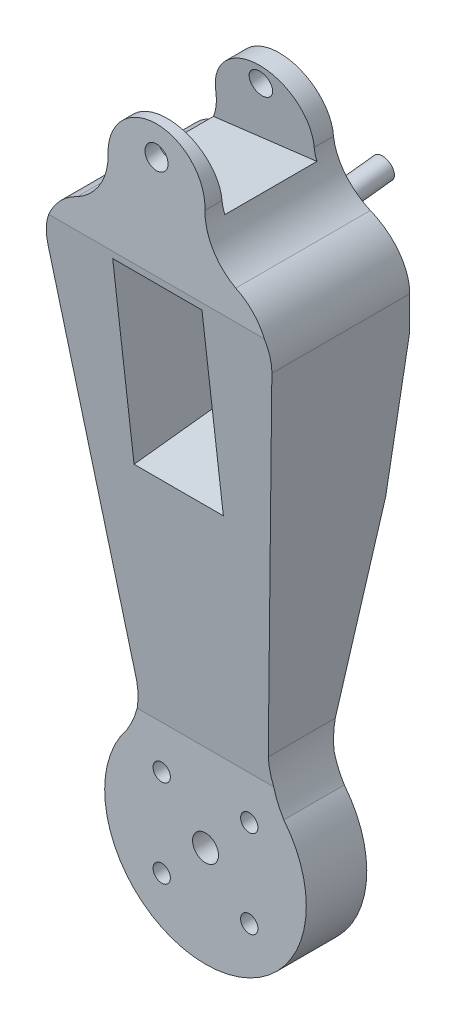
from build123d import *

# Parameters (mm, degrees)
BOSS_EXTRUDE1_DEPTH     = 55
CUT_EXTRUDE3_DEPTH      = 28
CUT_EXTRUDE4_DEPTH      = 40.029131656
CUT_EXTRUDE4_DEPTH_BACK = 40.029131656
SKETCH18_R              = 4.5
SKETCH18_R_2            = 3
CUT_EXTRUDE5_DEPTH      = 24.598674983
CUT_EXTRUDE5_DEPTH_BACK = 28
CUT_EXTRUDE6_DEPTH      = 26.134831719
CUT_EXTRUDE6_DEPTH_BACK = 85.175442033
SKETCH21_R              = 4
CUT_EXTRUDE7_DEPTH      = 25.226187847
CUT_EXTRUDE7_DEPTH_BACK = 56.443633682
SKETCH22_W              = 31
SKETCH22_H              = 66
CUT_EXTRUDE8_DEPTH      = 34
SKETCH30_R              = 3.775
BOSS_EXTRUDE2_DEPTH     = 30
CUT_EXTRUDE9_START      = 20
CUT_EXTRUDE9_DEPTH      = 15


with BuildPart() as part:
    # Sketch1 → Boss-Extrude1 (new body)
    with BuildSketch(Plane.XY):
        with BuildLine():
            Line((-22.827528122, 39.292617223), (-38.880054689, 170.029954628))
            ThreePointArc((-38.880054689, 170.029954628), (-36.535345881, 182.138559801), (-27.533199801, 190.569297881))
            ThreePointArc((-27.533199801, 190.569297881), (-19.660174006, 198.055084384), (-16.79086128, 208.533088928))
            ThreePointArc((-16.79086128, 208.533088928), (0, 226.212902341), (16.79086128, 208.533088928))
            ThreePointArc((16.79086128, 208.533088928), (19.660174006, 198.055084384), (27.533199801, 190.569297881))
            ThreePointArc((27.533199801, 190.569297881), (36.535345881, 182.138559801), (38.880054689, 170.029954628))
            Line((38.880054689, 170.029954628), (22.827528122, 39.292617223))
            ThreePointArc((22.827528122, 39.292617223), (23.667809595, 30.306601974), (27.215074691, 22.007719318))
            ThreePointArc((27.215074691, 22.007719318), (0, -35), (-27.215074691, 22.007719318))
            ThreePointArc((-27.215074691, 22.007719318), (-23.667809595, 30.306601974), (-22.827528122, 39.292617223))
        make_face()
    extrude(amount=BOSS_EXTRUDE1_DEPTH)

    # Sketch5 → Cut-Extrude3 (cut)
    with BuildSketch(Plane.XY):
        Polygon((16.97, -20.5), (-16.97, -20.5), (-20.5, -16.97), (-20.5, 16.97), (-16.97, 20.5), (16.97, 20.5), (20.5, 16.97), (20.5, -16.97), align=None)
    extrude(amount=CUT_EXTRUDE3_DEPTH, mode=Mode.SUBTRACT)

    # Sketch15 → Cut-Extrude4 (cut, two sides)
    with BuildSketch(Plane(origin=(0, 0, 0), x_dir=(0, 0, -1), z_dir=(1, 0, 0))) as cut_extrude4_sk:
        Polygon((-38, -35), (-38, 30.17907071), (-55, 180.299626254), (-55, -35), align=None)
        Polygon((-4.401325017, 156.123614829), (-12.400064416, 226.757450259), (0, 226.212902341), (0, 149.914783233), (0, 117.257182084), (0, -35), (-17, -35), (-17, 30.65016827), (-6.349536626, 105.369192589), align=None)
    extrude(amount=CUT_EXTRUDE4_DEPTH, mode=Mode.SUBTRACT)
    extrude(cut_extrude4_sk.sketch, amount=-CUT_EXTRUDE4_DEPTH_BACK, mode=Mode.SUBTRACT)

    # Sketch18 → Cut-Extrude5 (cut, two sides)
    with BuildSketch(Plane(origin=(0, 0, 28), x_dir=(-1, 0, 0), z_dir=(0, 0, -1))) as cut_extrude5_sk:
        Circle(SKETCH18_R)
        with Locations((-15.199466094, 15.199466094)):
            Circle(SKETCH18_R_2)
        with Locations((15.199466094, 15.199466094)):
            Circle(SKETCH18_R_2)
        with Locations((15.199466094, -15.199466094)):
            Circle(SKETCH18_R_2)
        with Locations((-15.199466094, -15.199466094)):
            Circle(SKETCH18_R_2)
    extrude(amount=CUT_EXTRUDE5_DEPTH, mode=Mode.SUBTRACT)
    extrude(cut_extrude5_sk.sketch, amount=-CUT_EXTRUDE5_DEPTH_BACK, mode=Mode.SUBTRACT)

    # Sketch20 → Cut-Extrude6 (cut, two sides)
    with BuildSketch(Plane(origin=(-17.735618329, -2.177660109, 0), x_dir=(0, 0, 1), z_dir=(-0.992546152, -0.121869343, 0))) as cut_extrude6_sk:
        Polygon((16.527188649, 200.652068787), (48.527188649, 200.652068787), (51.520800543, 224.652068787), (19.520800543, 224.652068787), align=None)
    extrude(amount=CUT_EXTRUDE6_DEPTH, mode=Mode.SUBTRACT)
    extrude(cut_extrude6_sk.sketch, amount=-CUT_EXTRUDE6_DEPTH_BACK, mode=Mode.SUBTRACT)

    # Sketch21 → Cut-Extrude7 (cut, two sides)
    with BuildSketch(Plane(origin=(0, -3.866612347, 34.144587862), x_dir=(1, 0, 0), z_dir=(0, -0.11252313, 0.993649106))) as cut_extrude7_sk:
        with Locations((0, 220.965020256)):
            Circle(SKETCH21_R)
    extrude(amount=CUT_EXTRUDE7_DEPTH, mode=Mode.SUBTRACT)
    extrude(cut_extrude7_sk.sketch, amount=-CUT_EXTRUDE7_DEPTH_BACK, mode=Mode.SUBTRACT)

    # Sketch22 → Cut-Extrude8 (cut)
    with BuildSketch(Plane(origin=(0, -3.866612347, 34.144587862), x_dir=(1, 0, 0), z_dir=(0, -0.11252313, 0.993649106))):
        with Locations((0, 149.850276465)):
            Rectangle(SKETCH22_W, SKETCH22_H)
    extrude(amount=-CUT_EXTRUDE8_DEPTH, mode=Mode.SUBTRACT)

    # Sketch30 → Boss-Extrude2 (add)
    with BuildSketch(Plane(origin=(0, 1.484646511, -13.110350529), x_dir=(-1, 0, 0), z_dir=(0, 0.11252313, -0.993649106))):
        with Locations((0, 169.857341116)):
            Circle(SKETCH30_R)
    extrude(amount=BOSS_EXTRUDE2_DEPTH)

    # Sketch31 → Cut-Extrude9 (cut)
    with BuildSketch(Plane.XY.offset(CUT_EXTRUDE9_START)):
        Polygon((-16.71237329, 40.092398344), (-23.538465204, 98.932300939), (19.683150051, 98.932300939), (14.908186254, 40.092398344), align=None)
    extrude(amount=CUT_EXTRUDE9_DEPTH, mode=Mode.SUBTRACT)


solid = part.part
